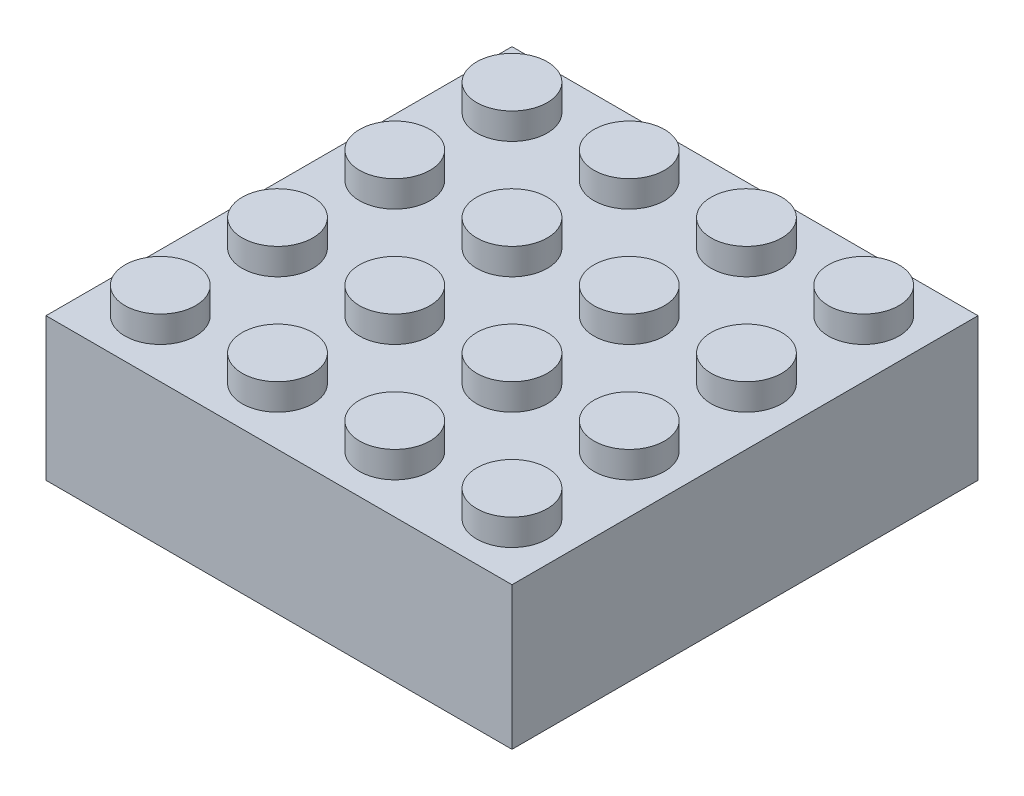
from build123d import *

# Parameters (mm, degrees)
SKETCH2_R              = 2.41
BOSS_EXTRUDE1_DEPTH    = 1.8
BOSS_EXTRUDE1_2_DEPTH  = 1.8
BOSS_EXTRUDE1_3_DEPTH  = 1.8
BOSS_EXTRUDE1_4_DEPTH  = 1.8
BOSS_EXTRUDE1_5_DEPTH  = 1.8
BOSS_EXTRUDE1_6_DEPTH  = 1.8
BOSS_EXTRUDE1_7_DEPTH  = 1.8
BOSS_EXTRUDE1_8_DEPTH  = 1.8
BOSS_EXTRUDE1_9_DEPTH  = 1.8
BOSS_EXTRUDE1_10_DEPTH = 1.8
BOSS_EXTRUDE1_11_DEPTH = 1.8
BOSS_EXTRUDE1_12_DEPTH = 1.8
BOSS_EXTRUDE1_13_DEPTH = 1.8
BOSS_EXTRUDE1_14_DEPTH = 1.8
BOSS_EXTRUDE1_15_DEPTH = 1.8
BOSS_EXTRUDE1_16_DEPTH = 1.8
SKETCH1_W              = 31.8
SKETCH1_H              = 31.8
BOSS_EXTRUDE2_DEPTH    = 9.73
CUT_EXTRUDE1_DEPTH     = 6.63


with BuildPart() as part:
    # Sketch2 → Boss-Extrude1 (new body)
    with BuildSketch(Plane(origin=(0, 0, 0), x_dir=(1, 0, 0), z_dir=(0, 1, 0))):
        with Locations((3.9, 27.9)):
            Circle(SKETCH2_R)
    extrude(amount=BOSS_EXTRUDE1_DEPTH)

    # Sketch1 → Boss-Extrude2 (add)
    with BuildSketch(Plane(origin=(0, 0, 0), x_dir=(1, 0, 0), z_dir=(0, 1, 0))):
        with Locations((15.9, 15.9)):
            Rectangle(SKETCH1_W, SKETCH1_H)
    extrude(amount=-BOSS_EXTRUDE2_DEPTH)

    # Sketch4 → Cut-Extrude1 (cut)
    with BuildSketch(Plane.XZ.offset(9.73)):
        Polygon((25.14, -15.9), (20.52, -7.897925269), (11.28, -7.897925269), (6.66, -15.9), (11.28, -23.902074731), (20.52, -23.902074731), align=None)
    extrude(amount=-CUT_EXTRUDE1_DEPTH, mode=Mode.SUBTRACT)


with BuildPart() as body_2:
    # Sketch2 → Boss-Extrude1 2 (new body)
    with BuildSketch(Plane(origin=(0, 0, 0), x_dir=(1, 0, 0), z_dir=(0, 1, 0))):
        with Locations((11.9, 27.9)):
            Circle(SKETCH2_R)
    extrude(amount=BOSS_EXTRUDE1_2_DEPTH)


with BuildPart() as body_3:
    # Sketch2 → Boss-Extrude1 3 (new body)
    with BuildSketch(Plane(origin=(0, 0, 0), x_dir=(1, 0, 0), z_dir=(0, 1, 0))):
        with Locations((19.9, 27.9)):
            Circle(SKETCH2_R)
    extrude(amount=BOSS_EXTRUDE1_3_DEPTH)


with BuildPart() as body_4:
    # Sketch2 → Boss-Extrude1 4 (new body)
    with BuildSketch(Plane(origin=(0, 0, 0), x_dir=(1, 0, 0), z_dir=(0, 1, 0))):
        with Locations((27.9, 27.9)):
            Circle(SKETCH2_R)
    extrude(amount=BOSS_EXTRUDE1_4_DEPTH)


with BuildPart() as body_5:
    # Sketch2 → Boss-Extrude1 5 (new body)
    with BuildSketch(Plane(origin=(0, 0, 0), x_dir=(1, 0, 0), z_dir=(0, 1, 0))):
        with Locations((11.9, 19.9)):
            Circle(SKETCH2_R)
    extrude(amount=BOSS_EXTRUDE1_5_DEPTH)


with BuildPart() as body_6:
    # Sketch2 → Boss-Extrude1 6 (new body)
    with BuildSketch(Plane(origin=(0, 0, 0), x_dir=(1, 0, 0), z_dir=(0, 1, 0))):
        with Locations((19.9, 19.9)):
            Circle(SKETCH2_R)
    extrude(amount=BOSS_EXTRUDE1_6_DEPTH)


with BuildPart() as body_7:
    # Sketch2 → Boss-Extrude1 7 (new body)
    with BuildSketch(Plane(origin=(0, 0, 0), x_dir=(1, 0, 0), z_dir=(0, 1, 0))):
        with Locations((27.9, 19.9)):
            Circle(SKETCH2_R)
    extrude(amount=BOSS_EXTRUDE1_7_DEPTH)


with BuildPart() as body_8:
    # Sketch2 → Boss-Extrude1 8 (new body)
    with BuildSketch(Plane(origin=(0, 0, 0), x_dir=(1, 0, 0), z_dir=(0, 1, 0))):
        with Locations((11.9, 11.9)):
            Circle(SKETCH2_R)
    extrude(amount=BOSS_EXTRUDE1_8_DEPTH)


with BuildPart() as body_9:
    # Sketch2 → Boss-Extrude1 9 (new body)
    with BuildSketch(Plane(origin=(0, 0, 0), x_dir=(1, 0, 0), z_dir=(0, 1, 0))):
        with Locations((19.9, 11.9)):
            Circle(SKETCH2_R)
    extrude(amount=BOSS_EXTRUDE1_9_DEPTH)


with BuildPart() as body_10:
    # Sketch2 → Boss-Extrude1 10 (new body)
    with BuildSketch(Plane(origin=(0, 0, 0), x_dir=(1, 0, 0), z_dir=(0, 1, 0))):
        with Locations((27.9, 11.9)):
            Circle(SKETCH2_R)
    extrude(amount=BOSS_EXTRUDE1_10_DEPTH)


with BuildPart() as body_11:
    # Sketch2 → Boss-Extrude1 11 (new body)
    with BuildSketch(Plane(origin=(0, 0, 0), x_dir=(1, 0, 0), z_dir=(0, 1, 0))):
        with Locations((11.9, 3.9)):
            Circle(SKETCH2_R)
    extrude(amount=BOSS_EXTRUDE1_11_DEPTH)


with BuildPart() as body_12:
    # Sketch2 → Boss-Extrude1 12 (new body)
    with BuildSketch(Plane(origin=(0, 0, 0), x_dir=(1, 0, 0), z_dir=(0, 1, 0))):
        with Locations((19.9, 3.9)):
            Circle(SKETCH2_R)
    extrude(amount=BOSS_EXTRUDE1_12_DEPTH)


with BuildPart() as body_13:
    # Sketch2 → Boss-Extrude1 13 (new body)
    with BuildSketch(Plane(origin=(0, 0, 0), x_dir=(1, 0, 0), z_dir=(0, 1, 0))):
        with Locations((27.9, 3.9)):
            Circle(SKETCH2_R)
    extrude(amount=BOSS_EXTRUDE1_13_DEPTH)


with BuildPart() as body_14:
    # Sketch2 → Boss-Extrude1 14 (new body)
    with BuildSketch(Plane(origin=(0, 0, 0), x_dir=(1, 0, 0), z_dir=(0, 1, 0))):
        with Locations((3.9, 19.9)):
            Circle(SKETCH2_R)
    extrude(amount=BOSS_EXTRUDE1_14_DEPTH)


with BuildPart() as body_15:
    # Sketch2 → Boss-Extrude1 15 (new body)
    with BuildSketch(Plane(origin=(0, 0, 0), x_dir=(1, 0, 0), z_dir=(0, 1, 0))):
        with Locations((3.9, 11.9)):
            Circle(SKETCH2_R)
    extrude(amount=BOSS_EXTRUDE1_15_DEPTH)


with BuildPart() as body_16:
    # Sketch2 → Boss-Extrude1 16 (new body)
    with BuildSketch(Plane(origin=(0, 0, 0), x_dir=(1, 0, 0), z_dir=(0, 1, 0))):
        with Locations((3.9, 3.9)):
            Circle(SKETCH2_R)
    extrude(amount=BOSS_EXTRUDE1_16_DEPTH)


solid = Compound([part.part, body_2.part, body_3.part, body_4.part, body_5.part, body_6.part, body_7.part, body_8.part, body_9.part, body_10.part, body_11.part, body_12.part, body_13.part, body_14.part, body_15.part, body_16.part])
